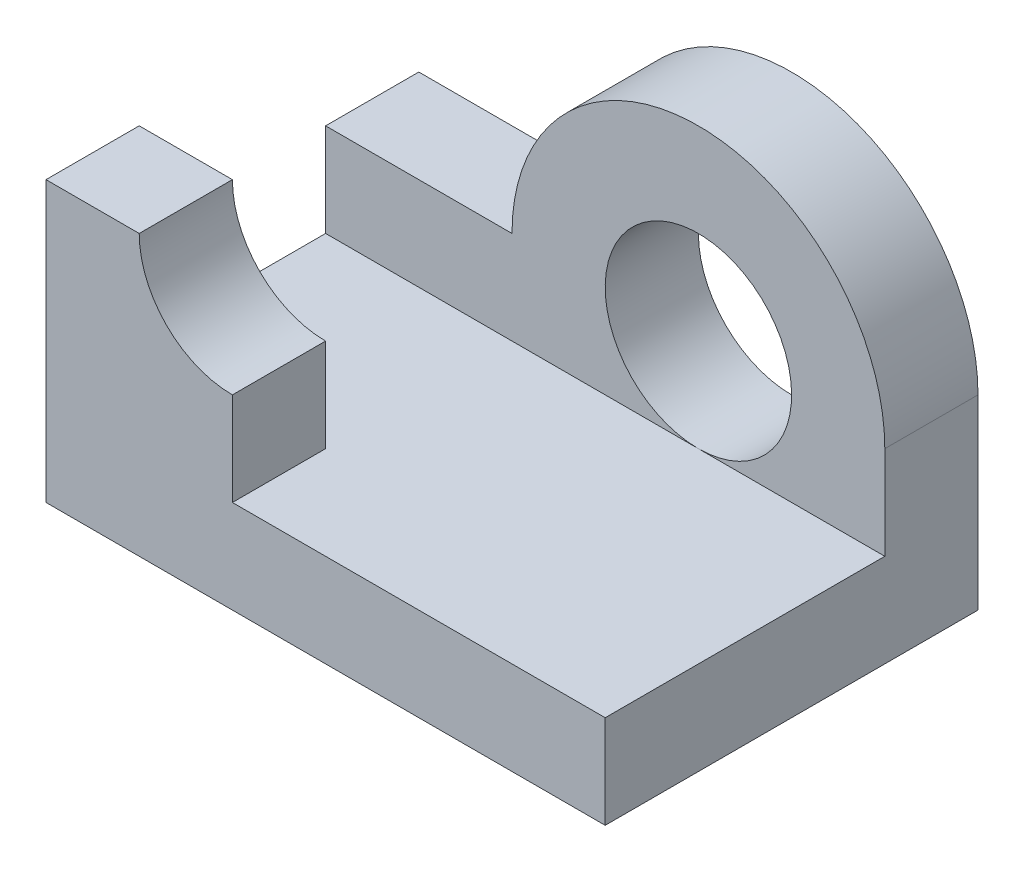
from build123d import *

# Parameters (mm, degrees)
SKETCH1_R           = 254
BOSS_EXTRUDE3_DEPTH = 254
BOSS_EXTRUDE4_DEPTH = 1016
BOSS_EXTRUDE5_START = 762
BOSS_EXTRUDE5_DEPTH = 254


with BuildPart() as part:
    # Sketch1 → Boss-Extrude3 (new body)
    with BuildSketch(Plane.XY):
        with BuildLine():
            Line((0, 0), (1524, 0))
            Line((1524, 0), (1524, 508))
            ThreePointArc((1524, 508), (1016, 1016), (508, 508))
            Line((508, 508), (0, 508))
            Line((0, 508), (0, 0))
        make_face()
        with Locations((1016, 508)):
            Circle(SKETCH1_R, mode=Mode.SUBTRACT)
    extrude(amount=BOSS_EXTRUDE3_DEPTH)

    # Sketch1_8 → Boss-Extrude4 (add)
    with BuildSketch(Plane.XY):
        Polygon((0, 254), (0, 0), (1524, 0), (1524, 254), (1016, 254), (508, 254), align=None)
    extrude(amount=BOSS_EXTRUDE4_DEPTH)

    # Sketch1_9 → Boss-Extrude5 (add)
    with BuildSketch(Plane.XY.offset(BOSS_EXTRUDE5_START)):
        with BuildLine():
            Line((0, 254), (508, 254))
            Line((508, 254), (508, 508))
            ThreePointArc((508, 508), (328.394877579, 582.394877579), (254, 762))
            Line((254, 762), (0, 762))
            Line((0, 762), (0, 254))
        make_face()
    extrude(amount=BOSS_EXTRUDE5_DEPTH)


solid = part.part
